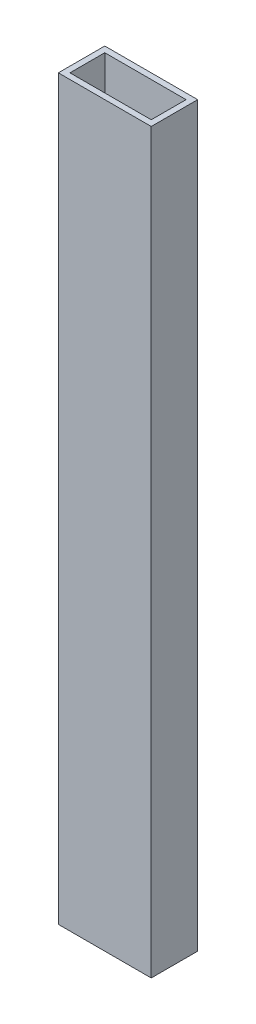
from build123d import *

# Parameters (mm, degrees)
SKETCH1_W           = 50.8
SKETCH1_H           = 25.4
SKETCH1_W_2         = 44.45
SKETCH1_H_2         = 19.05
BOSS_EXTRUDE1_DEPTH = 403.225


with BuildPart() as part:
    # Sketch1 → Boss-Extrude1 (new body)
    with BuildSketch(Plane(origin=(0, 0, 0), x_dir=(1, 0, 0), z_dir=(0, 1, 0))):
        with Locations((25.4, 12.7)):
            Rectangle(SKETCH1_W, SKETCH1_H)
        with Locations((25.4, 12.7)):
            Rectangle(SKETCH1_W_2, SKETCH1_H_2, mode=Mode.SUBTRACT)
    extrude(amount=BOSS_EXTRUDE1_DEPTH)


solid = part.part
